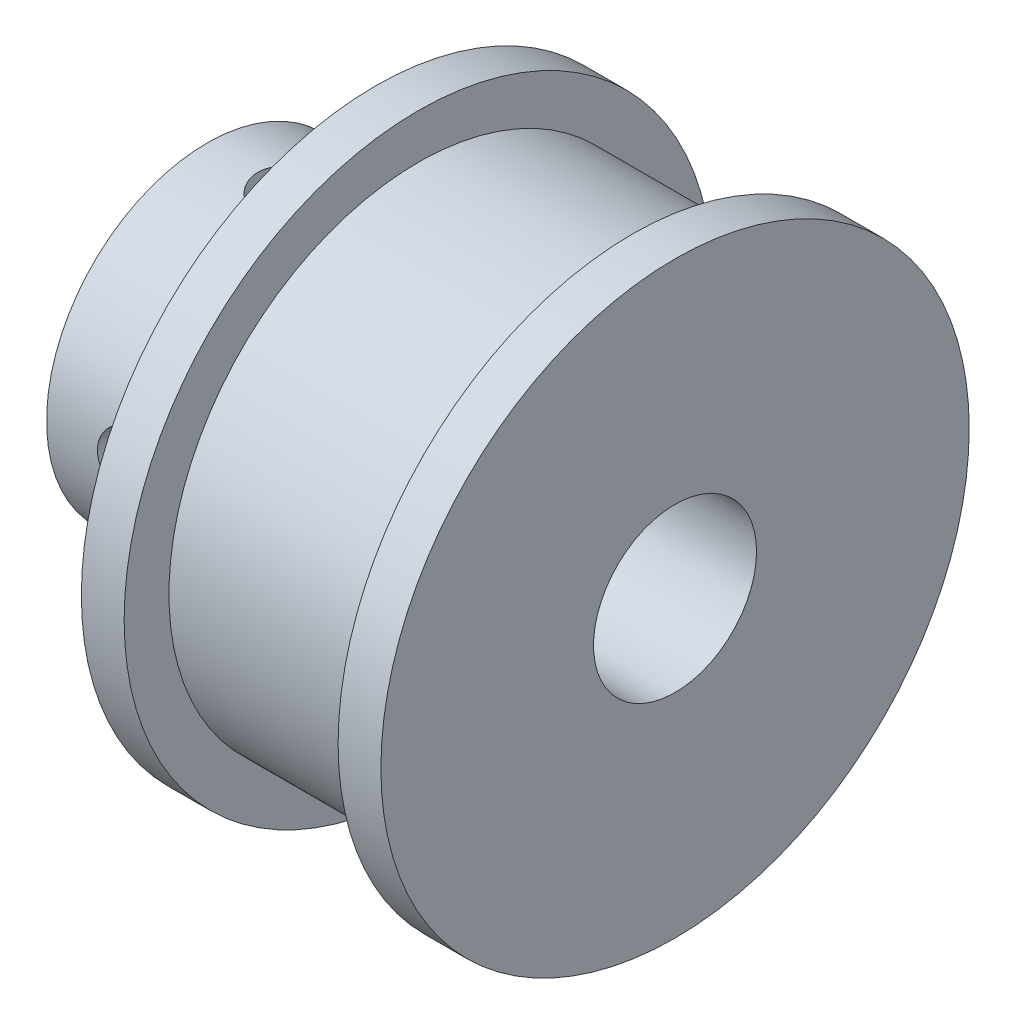
from build123d import *

# Parameters (mm, degrees)
SKETCH2_W          = 1.25
SKETCH2_H          = 11
SKETCH4_W          = 1.25
SKETCH4_H          = 11
SKETCH6_R          = 3.048
CUT_EXTRUDE1_DEPTH = 18.5000001


with BuildPart() as part:
    # Sketch1 → Revolve1 (revolve)
    with BuildSketch(Plane.XY):
        Polygon((0, 2.5), (0, 6), (6.3, 6), (6.3, 11), (7.9, 11), (7.9, 9.325), (15.9, 9.325), (15.9, 11), (17.5, 11), (17.5, 2.5), align=None)
    revolve(axis=Axis((0, 0, 0), (-1, 0, 0)))

    # Sketch2 → M3x0.5 Tapped Hole1 (revolve, cut)
    with BuildSketch(Plane(origin=(3.15, 0, 0), x_dir=(0, 0, -1), z_dir=(1, 0, 0))):
        with Locations((0.625, 5.5)):
            Rectangle(SKETCH2_W, SKETCH2_H)
    revolve(axis=Axis((3.15, -6.35, 0), (0, 1, 0)), mode=Mode.SUBTRACT)

    # Sketch4 → M3x0.5 Tapped Hole2 (revolve, cut)
    with BuildSketch(Plane.YZ.offset(3.15)):
        with Locations((0.625, 5.5)):
            Rectangle(SKETCH4_W, SKETCH4_H)
    revolve(axis=Axis((3.15, 0, -6.35), (0, 0, 1)), mode=Mode.SUBTRACT)

    # Sketch6 → Cut-Extrude1 (cut, through all)
    with BuildSketch(Plane(origin=(17.5, 0, 0), x_dir=(0, 0, -1), z_dir=(1, 0, 0))):
        Circle(SKETCH6_R)
    extrude(amount=-CUT_EXTRUDE1_DEPTH, mode=Mode.SUBTRACT)


solid = part.part
